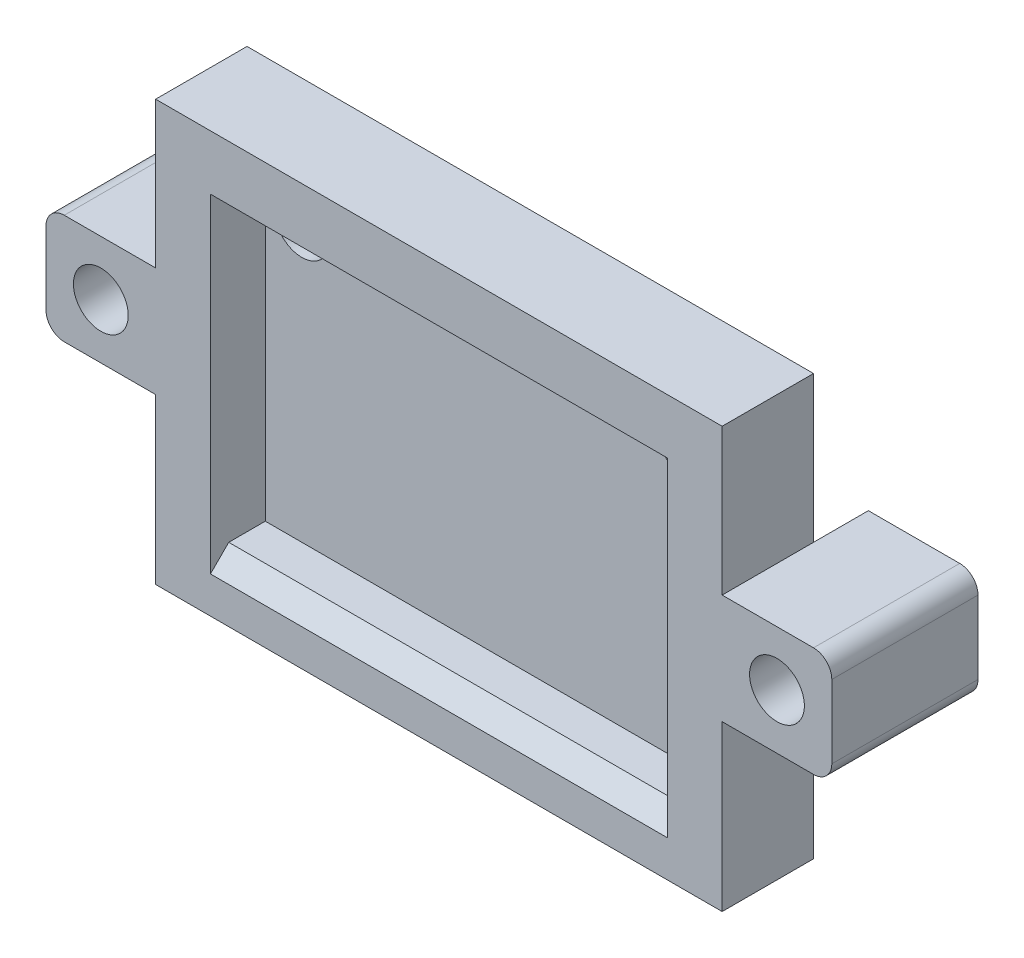
from build123d import *

# Parameters (mm, degrees)
ESQUISSE1_W             = 31
ESQUISSE1_H             = 23
BOSS_EXTRU_1_DEPTH      = 5
ESQUISSE2_W             = 25
ESQUISSE2_H             = 17
ENL_V_MAT_EXTRU_1_DEPTH = 3
ESQUISSE4_W             = 6
ESQUISSE4_H             = 6
BOSS_EXTRU_3_DEPTH      = 8
CHANFREIN2_SIZE         = 1
CONG_2_R                = 1
ESQUISSE3_R             = 1.5
ENL_V_MAT_EXTRU_2_DEPTH = 3
ESQUISSE5_R             = 1.5
ENL_V_MAT_EXTRU_3_DEPTH = 9


with BuildPart() as part:
    # Esquisse1 → Boss.-Extru.1 (new body)
    with BuildSketch(Plane.XY):
        with Locations((-15.5, 11.5)):
            Rectangle(ESQUISSE1_W, ESQUISSE1_H)
    extrude(amount=BOSS_EXTRU_1_DEPTH)

    # Esquisse2 → Enlèv. mat.-Extru.1 (cut)
    with BuildSketch(Plane.XY.offset(5)):
        with Locations((-15.5, 11.5)):
            Rectangle(ESQUISSE2_W, ESQUISSE2_H)
    extrude(amount=-ENL_V_MAT_EXTRU_1_DEPTH, mode=Mode.SUBTRACT)

    # Esquisse4 → Boss.-Extru.3 (add)
    with BuildSketch(Plane.XY.offset(5)):
        with Locations((-34, 12)):
            Rectangle(ESQUISSE4_W, ESQUISSE4_H)
        with Locations((3, 12)):
            Rectangle(ESQUISSE4_W, ESQUISSE4_H)
    extrude(amount=-BOSS_EXTRU_3_DEPTH)

    # Chanfrein2
    chanfrein2_edges = [part.edges().sort_by_distance(p)[0] for p in [
        (-15.5, 3, 5),
    ]]
    chamfer(chanfrein2_edges, length=CHANFREIN2_SIZE)

    # Congé2
    cong_2_edges = [part.edges().sort_by_distance(p)[0] for p in [
        (-37, 15, 1),
        (6, 15, 1),
        (6, 9, 1),
        (-37, 9, 1),
    ]]
    fillet(cong_2_edges, radius=CONG_2_R)

    # Esquisse3 → Enlèv. mat.-Extru.2 (cut)
    with BuildSketch(Plane.XY.offset(2)):
        with Locations((-26, 18)):
            Circle(ESQUISSE3_R)
        with Locations((-5, 18)):
            Circle(ESQUISSE3_R)
    extrude(amount=-ENL_V_MAT_EXTRU_2_DEPTH, mode=Mode.SUBTRACT)

    # Esquisse5 → Enlèv. mat.-Extru.3 (cut, through all)
    with BuildSketch(Plane.XY.offset(5)):
        with Locations((-34, 12)):
            Circle(ESQUISSE5_R)
        with Locations((3, 12)):
            Circle(ESQUISSE5_R)
    extrude(amount=-ENL_V_MAT_EXTRU_3_DEPTH, mode=Mode.SUBTRACT)


solid = part.part
